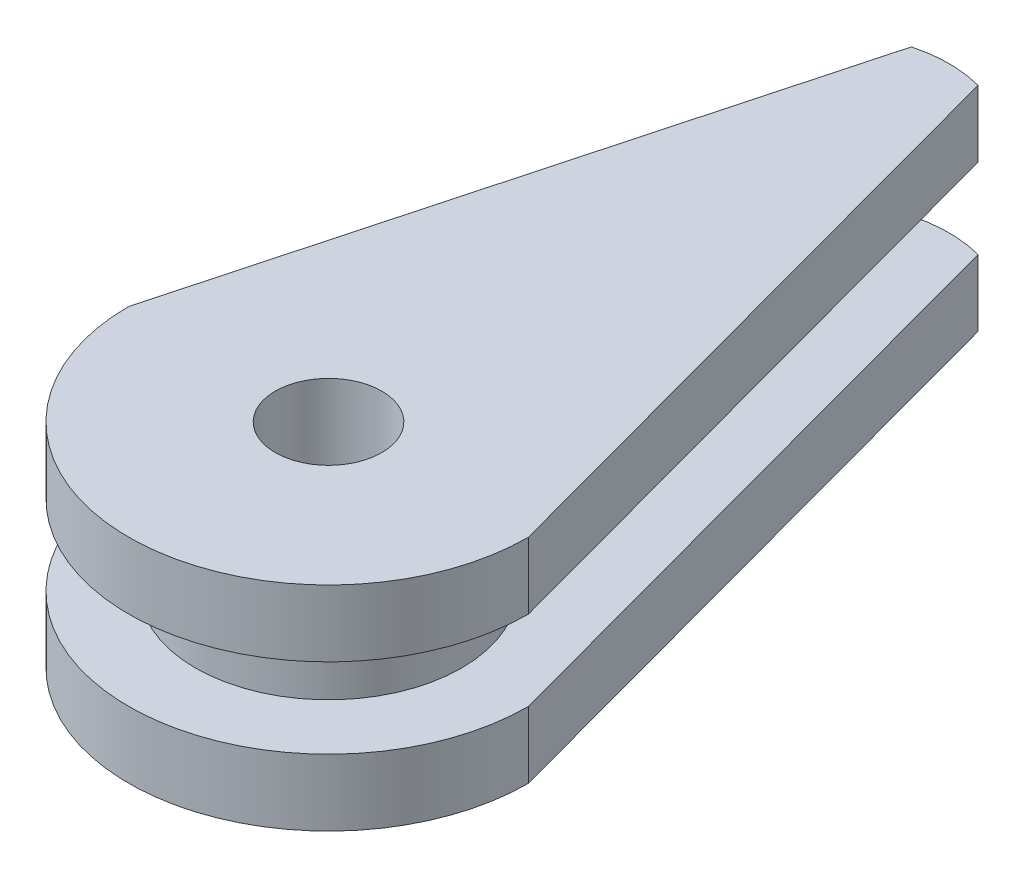
from build123d import *

# Parameters (mm, degrees)
SKETCH_1_R          = 5
EXTRUDE_1_DEPTH     = 3
EXTRUDE_3_DEPTH     = 2.5
EXTRUDE_4_DEPTH     = 2.5
EXTRUDE_START       = -8
EXTRUDE_5_DEPTH     = 2.5
SKETCH_9_R          = 2
CUT_EXTRUDE_1_DEPTH = 9


with BuildPart() as part:
    # 草图1 → 凸台-拉伸1 (new body)
    with BuildSketch(Plane(origin=(0, 0, 0), x_dir=(1, 0, 0), z_dir=(0, 1, 0))):
        Circle(SKETCH_1_R)
    extrude(amount=EXTRUDE_1_DEPTH)

    # 草图6 → 凸台-拉伸3 (add)
    with BuildSketch(Plane.XZ):
        with BuildLine():
            Line((0, -5), (0, 5))
            ThreePointArc((0, 5), (-3.535533906, 3.535533906), (-5, 0))
            Line((-5, 0), (-4.319264806, -2.518720218))
            ThreePointArc((-4.319264806, -2.518720218), (-2.490622303, -4.335527712), (0, -5))
        make_face()
        with BuildLine():
            Line((0, -18.5), (0, -5))
            ThreePointArc((0, -5), (-2.490622303, -4.335527712), (-4.319264806, -2.518720218))
            Line((-4.319264806, -2.518720218), (0, -18.5))
        make_face()
        with BuildLine():
            ThreePointArc((5, 0), (3.535533906, 3.535533906), (0, 5))
            Line((0, 5), (0, -5))
            ThreePointArc((0, -5), (2.490622303, -4.335527712), (4.319264806, -2.518720218))
            Line((4.319264806, -2.518720218), (5, 0))
        make_face()
        with BuildLine():
            ThreePointArc((4.319264806, -2.518720218), (2.490622303, -4.335527712), (0, -5))
            Line((0, -5), (0, -18.5))
            Line((0, -18.5), (4.319264806, -2.518720218))
        make_face()
    extrude_3 = extrude(amount=EXTRUDE_3_DEPTH)

    # 镜向1: 凸台-拉伸3 across plane
    add(extrude_3.mirror(Plane.ZX.offset(1.5)))

    # 草图8 → 凸台-拉伸4 (add)
    with BuildSketch(Plane(origin=(0, 5.5, 0), x_dir=(1, 0, 0), z_dir=(0, 1, 0))):
        with BuildLine():
            Line((1.25, 23.125), (0, 18.5))
            Line((0, 18.5), (-1.25, 23.125))
            Line((-1.25, 23.125), (-7.5, 0))
            ThreePointArc((-7.5, 0), (0, -7.5), (7.5, 0))
            Line((7.5, 0), (1.25, 23.125))
        make_face()
        with BuildLine():
            Line((-5, 0), (0, 18.5))
            Line((0, 18.5), (5, 0))
            ThreePointArc((5, 0), (0, -5), (-5, 0))
        make_face(mode=Mode.SUBTRACT)
        with BuildLine():
            Line((-1.25, 23.125), (0, 18.5))
            Line((0, 18.5), (1.25, 23.125))
            ThreePointArc((1.25, 23.125), (0, 23.290941974), (-1.25, 23.125))
        make_face()
    extrude(amount=-EXTRUDE_4_DEPTH)

    # 草图8<4> → 凸台-拉伸5 (add)
    with BuildSketch(Plane(origin=(0, 5.5, 0), x_dir=(1, 0, 0), z_dir=(0, 1, 0)).offset(EXTRUDE_START)):
        with BuildLine():
            Line((-7.5, 0), (-1.25, 23.125))
            ThreePointArc((-1.25, 23.125), (0, 23.290941974), (1.25, 23.125))
            Line((1.25, 23.125), (7.5, 0))
            ThreePointArc((7.5, 0), (0, -7.5), (-7.5, 0))
        make_face()
    extrude(amount=EXTRUDE_5_DEPTH)

    # 草图9 → 切除-拉伸1 (cut, through all)
    with BuildSketch(Plane.XZ.offset(2.5)):
        Circle(SKETCH_9_R)
    extrude(amount=-CUT_EXTRUDE_1_DEPTH, mode=Mode.SUBTRACT)


solid = part.part
